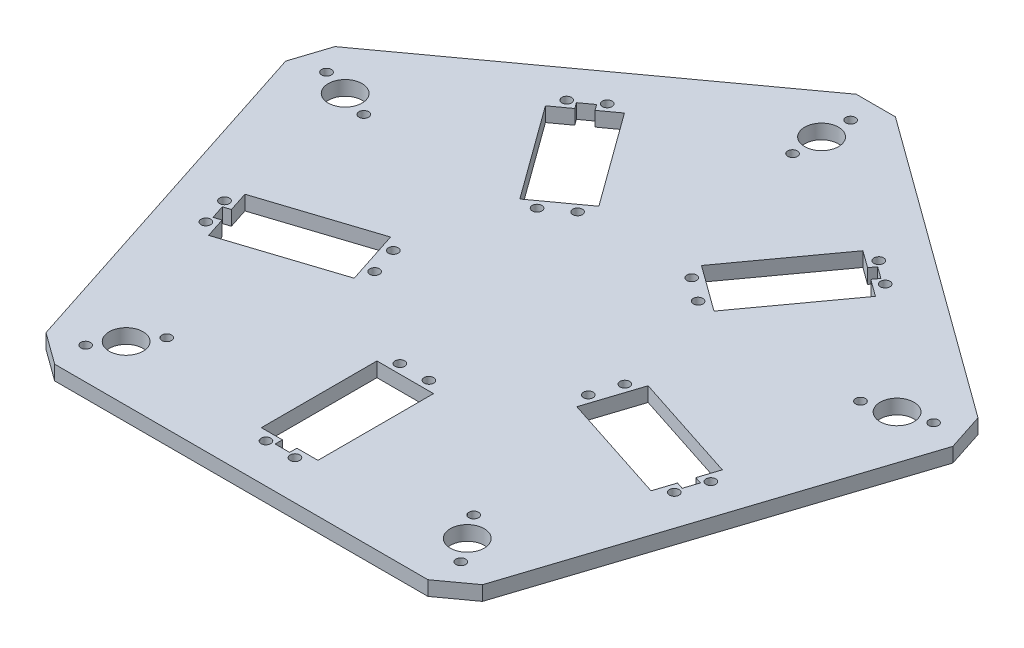
from build123d import *

# Parameters (mm, degrees)
ESQUISSE2_R        = 3.5
ESQUISSE2_R_2      = 1
BOSS_EXTRU_1_DEPTH = 3
CHANFREIN2_SIZE    = 5


with BuildPart() as part:
    # Esquisse2 → Boss.-Extru.1 (new body)
    with BuildSketch(Plane(origin=(0, 0, 0), x_dir=(1, 0, 0), z_dir=(0, 1, 0))):
        Polygon((70.534230275, 22.917960675), (0, 74.16407865), (-70.534230275, 22.917960675), (-43.59255168, -60), (43.59255168, -60), align=None)
        with Locations((-57.063390978, 18.541019662)):
            Circle(ESQUISSE2_R, mode=Mode.SUBTRACT)
        with Locations((0, 60)):
            Circle(ESQUISSE2_R, mode=Mode.SUBTRACT)
        with Locations((57.063390978, 18.541019662)):
            Circle(ESQUISSE2_R, mode=Mode.SUBTRACT)
        with Locations((35.267115138, -48.541019662)):
            Circle(ESQUISSE2_R, mode=Mode.SUBTRACT)
        with Locations((-35.267115138, -48.541019662)):
            Circle(ESQUISSE2_R, mode=Mode.SUBTRACT)
        with Locations((-62.769730075, 20.395121629)):
            Circle(ESQUISSE2_R_2, mode=Mode.SUBTRACT)
        with Locations((-51.35705188, 16.686917696)):
            Circle(ESQUISSE2_R_2, mode=Mode.SUBTRACT)
        with Locations((0, 66)):
            Circle(ESQUISSE2_R_2, mode=Mode.SUBTRACT)
        with Locations((0, 54)):
            Circle(ESQUISSE2_R_2, mode=Mode.SUBTRACT)
        with Locations((62.769730075, 20.395121629)):
            Circle(ESQUISSE2_R_2, mode=Mode.SUBTRACT)
        with Locations((51.35705188, 16.686917696)):
            Circle(ESQUISSE2_R_2, mode=Mode.SUBTRACT)
        with Locations((38.793826651, -53.395121629)):
            Circle(ESQUISSE2_R_2, mode=Mode.SUBTRACT)
        with Locations((31.740403624, -43.686917696)):
            Circle(ESQUISSE2_R_2, mode=Mode.SUBTRACT)
        with Locations((-38.793826651, -53.395121629)):
            Circle(ESQUISSE2_R_2, mode=Mode.SUBTRACT)
        with Locations((-31.740403624, -43.686917696)):
            Circle(ESQUISSE2_R_2, mode=Mode.SUBTRACT)
        with Locations((-3, -51.9)):
            Circle(ESQUISSE2_R_2, mode=Mode.SUBTRACT)
        with Locations((3, -51.9)):
            Circle(ESQUISSE2_R_2, mode=Mode.SUBTRACT)
        with Locations((3, -24.2)):
            Circle(ESQUISSE2_R_2, mode=Mode.SUBTRACT)
        with Locations((-3, -24.2)):
            Circle(ESQUISSE2_R_2, mode=Mode.SUBTRACT)
        with Locations((-23.942618677, -4.625041715)):
            Circle(ESQUISSE2_R_2, mode=Mode.SUBTRACT)
        with Locations((-22.088516711, -10.331380813)):
            Circle(ESQUISSE2_R_2, mode=Mode.SUBTRACT)
        with Locations((-48.432782213, -18.891151557)):
            Circle(ESQUISSE2_R_2, mode=Mode.SUBTRACT)
        with Locations((-50.286884179, -13.184812459)):
            Circle(ESQUISSE2_R_2, mode=Mode.SUBTRACT)
        with Locations((-11.797352122, 21.341567021)):
            Circle(ESQUISSE2_R_2, mode=Mode.SUBTRACT)
        with Locations((-16.651454089, 17.814855507)):
            Circle(ESQUISSE2_R_2, mode=Mode.SUBTRACT)
        with Locations((-32.933105577, 40.224626251)):
            Circle(ESQUISSE2_R_2, mode=Mode.SUBTRACT)
        with Locations((-28.079003611, 43.751337765)):
            Circle(ESQUISSE2_R_2, mode=Mode.SUBTRACT)
        with Locations((16.651454089, 17.814855507)):
            Circle(ESQUISSE2_R_2, mode=Mode.SUBTRACT)
        with Locations((11.797352122, 21.341567021)):
            Circle(ESQUISSE2_R_2, mode=Mode.SUBTRACT)
        with Locations((28.079003611, 43.751337765)):
            Circle(ESQUISSE2_R_2, mode=Mode.SUBTRACT)
        with Locations((32.933105577, 40.224626251)):
            Circle(ESQUISSE2_R_2, mode=Mode.SUBTRACT)
        with Locations((22.088516711, -10.331380813)):
            Circle(ESQUISSE2_R_2, mode=Mode.SUBTRACT)
        with Locations((23.942618677, -4.625041715)):
            Circle(ESQUISSE2_R_2, mode=Mode.SUBTRACT)
        with Locations((50.286884179, -13.184812459)):
            Circle(ESQUISSE2_R_2, mode=Mode.SUBTRACT)
        with Locations((48.432782213, -18.891151557)):
            Circle(ESQUISSE2_R_2, mode=Mode.SUBTRACT)
        Polygon((-5.85, -26.1), (5.85, -26.1), (5.85, -50), (1.5, -50), (1.5, -51.5), (-1.5, -51.5), (-1.5, -50), (-5.85, -50), align=None, mode=Mode.SUBTRACT)
        Polygon((-23.014825658, -13.629024174), (-45.745076398, -21.014530339), (-47.089300323, -16.877434493), (-48.515885098, -17.340959985), (-49.442936081, -14.487790436), (-48.016351306, -14.024264944), (-49.360575232, -9.887169098), (-26.630324492, -2.501662933), align=None, mode=Mode.SUBTRACT)
        Polygon((-20.073944502, 17.676799827), (-34.122012032, 37.012305993), (-30.602788106, 39.56917184), (-31.484465985, 40.782697332), (-29.057415001, 42.546053089), (-28.175737123, 41.332527597), (-24.656513198, 43.889393445), (-10.608445668, 24.553887279), align=None, mode=Mode.SUBTRACT)
        Polygon((10.608445668, 24.553887279), (24.656513198, 43.889393445), (28.175737123, 41.332527597), (29.057415001, 42.546053089), (31.484465985, 40.782697332), (30.602788106, 39.56917184), (34.122012032, 37.012305993), (20.073944502, 17.676799827), align=None, mode=Mode.SUBTRACT)
        Polygon((26.630324492, -2.501662933), (49.360575232, -9.887169098), (48.016351306, -14.024264944), (49.442936081, -14.487790436), (48.515885098, -17.340959985), (47.089300323, -16.877434493), (45.745076398, -21.014530339), (23.014825658, -13.629024174), align=None, mode=Mode.SUBTRACT)
    extrude(amount=BOSS_EXTRU_1_DEPTH)

    # Chanfrein2
    chanfrein2_edges = [part.edges().sort_by_distance(p)[0] for p in [
        (43.59255168, 1.5, 60),
        (-43.59255168, 1.5, 60),
        (-70.534230275, 1.5, -22.917960675),
        (0, 1.5, -74.16407865),
        (70.534230275, 1.5, -22.917960675),
    ]]
    chamfer(chanfrein2_edges, length=CHANFREIN2_SIZE)


solid = part.part
